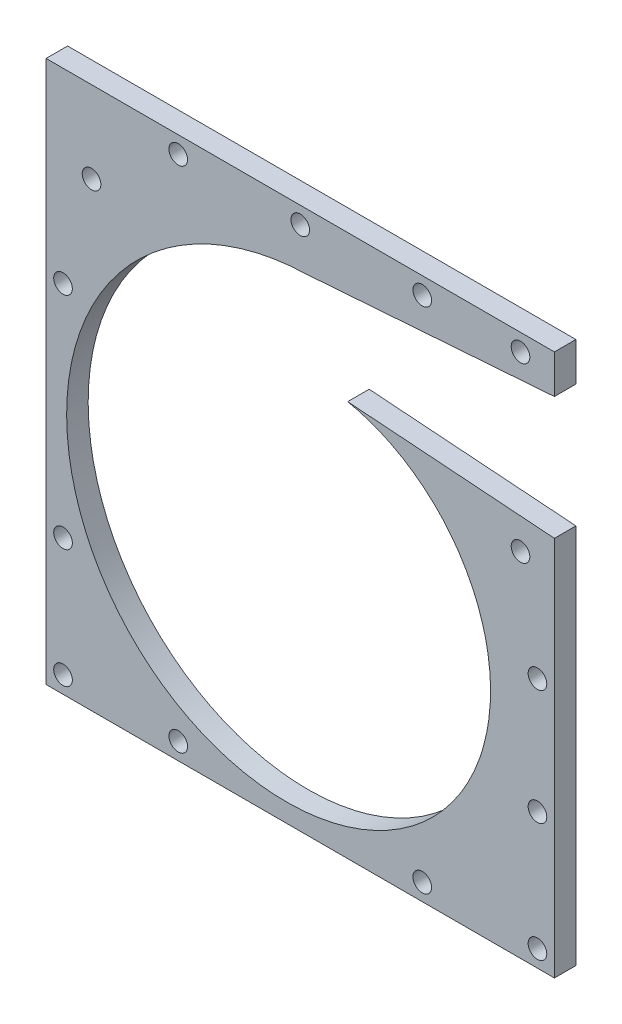
from build123d import *

# Parameters (mm, degrees)
SKETCH1_W           = 150
SKETCH1_H           = 160
BOSS_EXTRUDE1_DEPTH = 6.35
CUT_EXTRUDE2_REACH  = 8.35
SKETCH2_R           = 50
CUT_EXTRUDE3_REACH  = 8.35
CUT_EXTRUDE4_REACH  = 8.35
SKETCH9_R           = 2.75


with BuildPart() as part:
    # Sketch1 → Boss-Extrude1 (new body)
    with BuildSketch(Plane.XY):
        with Locations((56.818174671, 72.21769967)):
            Rectangle(SKETCH1_W, SKETCH1_H)
    extrude(amount=BOSS_EXTRUDE1_DEPTH)

    # Sketch2 → Cut-Extrude2 (cut, up to next)
    with BuildSketch(Plane.XY, mode=Mode.PRIVATE) as cut_extrude2_sk1:
        with Locations((56.818174671, 60.21769967)):
            Circle(SKETCH2_R)
    cut_extrude2_tool1 = extrude(cut_extrude2_sk1.sketch, amount=CUT_EXTRUDE2_REACH, mode=Mode.PRIVATE) & part.part
    add(cut_extrude2_tool1.solids().sort_by_distance((56.818175, 60.2177, 0))[0], mode=Mode.SUBTRACT)

    # Sketch8 → Cut-Extrude3 (cut, up to next)
    with BuildSketch(Plane.XY.offset(6.35), mode=Mode.PRIVATE) as cut_extrude3_sk1:
        with BuildLine():
            Line((58.92140003, 135.514331195), (131.818174671, 140.809388743))
            Line((131.818174671, 140.809388743), (131.818174671, 104.578808843))
            Line((131.818174671, 104.578808843), (70.806770479, 109.001730739))
            add(Edge.make_bspline(
                [(70.806770479, 109.001730739), (73.942524714, 108.368884336), (77.04178439, 107.432911602), (83.051183235, 104.970960127), (85.961176799, 103.444994734), (91.479272622, 99.84171719), (94.08723275, 97.764446671), (98.896476379, 93.118835241), (101.097626722, 90.550563372), (105.000601765, 85.003178114), (106.702307564, 82.024159237), (109.529682116, 75.752999351), (110.655251092, 72.460975365), (112.272876974, 65.675829551), (112.764857474, 62.18284337), (113.079726502, 55.118296179), (112.902565452, 51.546884758), (111.867369097, 44.454211174), (111.009313557, 40.93310722), (108.625399649, 34.071335338), (107.099551849, 30.730828472), (103.418128221, 24.357288168), (101.262594088, 21.324412639), (96.384092178, 15.685114778), (93.661196375, 13.078841183), (87.732775622, 8.399046081), (84.527350913, 6.325658336), (77.738594716, 2.80099297), (74.155388616, 1.34982877), (66.732312128, -0.861700607), (62.892588137, -1.621977418), (55.090144524, -2.406756839), (51.127587291, -2.431200011), (43.220919756, -1.725282069), (39.276982107, -0.994893308), (31.551721516, 1.212456983), (27.77057526, 2.689412638), (20.512525514, 6.354071351), (17.035796228, 8.541734506), (10.520379708, 13.56507488), (7.481857639, 16.400678926), (1.963709861, 22.631960147), (-0.515766072, 26.027532897), (-4.812661012, 33.268276111), (-6.629951535, 37.113314132), (-9.521205366, 45.123544829), (-10.595066712, 49.288581387), (-11.94355863, 57.794744944), (-12.218118102, 62.135697466), (-11.940081486, 70.8399882), (-11.387448434, 75.203139684), (-9.456713485, 83.793925735), (-8.078610826, 88.021368007), (-4.52880765, 96.184347178), (-2.357143331, 100.119693237), (2.718257783, 107.549380476), (5.621922023, 111.043539373), (12.071778181, 117.454666429), (15.617863156, 120.371467783), (23.237698029, 125.509870744), (27.311309881, 127.731327501), (35.849706709, 131.383908814), (40.314327037, 132.814916259), (49.481179121, 134.818294383), (54.183225201, 135.390580553), (58.92140003, 135.514331195)],
                knots=[0, 0, 0, 0, 0.03125, 0.03125, 0.0625, 0.0625, 0.09375, 0.09375, 0.125, 0.125, 0.15625, 0.15625, 0.1875, 0.1875, 0.21875, 0.21875, 0.25, 0.25, 0.28125, 0.28125, 0.3125, 0.3125, 0.34375, 0.34375, 0.375, 0.375, 0.40625, 0.40625, 0.4375, 0.4375, 0.46875, 0.46875, 0.5, 0.5, 0.53125, 0.53125, 0.5625, 0.5625, 0.59375, 0.59375, 0.625, 0.625, 0.65625, 0.65625, 0.6875, 0.6875, 0.71875, 0.71875, 0.75, 0.75, 0.78125, 0.78125, 0.8125, 0.8125, 0.84375, 0.84375, 0.875, 0.875, 0.90625, 0.90625, 0.9375, 0.9375, 0.96875, 0.96875, 1, 1, 1, 1], degree=3))
        make_face()
    cut_extrude3_tool1 = extrude(cut_extrude3_sk1.sketch, amount=-CUT_EXTRUDE3_REACH, mode=Mode.PRIVATE) & part.part
    add(cut_extrude3_tool1.solids().sort_by_distance((56.233786, 70.895416, 6.35))[0], mode=Mode.SUBTRACT)

    # Sketch9 → Cut-Extrude4 (cut, up to next)
    with BuildSketch(Plane.XY.offset(6.35), mode=Mode.PRIVATE) as cut_extrude4_sk1:
        with Locations((121.818174671, 147.21769967)):
            Circle(SKETCH9_R)
    cut_extrude4_tool1 = extrude(cut_extrude4_sk1.sketch, amount=-CUT_EXTRUDE4_REACH, mode=Mode.PRIVATE) & part.part
    add(cut_extrude4_tool1.solids().sort_by_distance((121.818175, 147.2177, 6.35))[0], mode=Mode.SUBTRACT)
    # Sketch9 → Cut-Extrude4 (cut, up to next)
    with BuildSketch(Plane.XY.offset(6.35), mode=Mode.PRIVATE) as cut_extrude4_sk2:
        with Locations((92.818174671, 147.21769967)):
            Circle(SKETCH9_R)
    cut_extrude4_tool2 = extrude(cut_extrude4_sk2.sketch, amount=-CUT_EXTRUDE4_REACH, mode=Mode.PRIVATE) & part.part
    add(cut_extrude4_tool2.solids().sort_by_distance((92.818175, 147.2177, 6.35))[0], mode=Mode.SUBTRACT)
    # Sketch9 → Cut-Extrude4 (cut, up to next)
    with BuildSketch(Plane.XY.offset(6.35), mode=Mode.PRIVATE) as cut_extrude4_sk3:
        with Locations((56.818174671, 147.21769967)):
            Circle(SKETCH9_R)
    cut_extrude4_tool3 = extrude(cut_extrude4_sk3.sketch, amount=-CUT_EXTRUDE4_REACH, mode=Mode.PRIVATE) & part.part
    add(cut_extrude4_tool3.solids().sort_by_distance((56.818175, 147.2177, 6.35))[0], mode=Mode.SUBTRACT)
    # Sketch9 → Cut-Extrude4 (cut, up to next)
    with BuildSketch(Plane.XY.offset(6.35), mode=Mode.PRIVATE) as cut_extrude4_sk4:
        with Locations((20.818174671, 147.21769967)):
            Circle(SKETCH9_R)
    cut_extrude4_tool4 = extrude(cut_extrude4_sk4.sketch, amount=-CUT_EXTRUDE4_REACH, mode=Mode.PRIVATE) & part.part
    add(cut_extrude4_tool4.solids().sort_by_distance((20.818175, 147.2177, 6.35))[0], mode=Mode.SUBTRACT)
    # Sketch9 → Cut-Extrude4 (cut, up to next)
    with BuildSketch(Plane.XY.offset(6.35), mode=Mode.PRIVATE) as cut_extrude4_sk5:
        with Locations((-4.774596198, 128.093555907)):
            Circle(SKETCH9_R)
    cut_extrude4_tool5 = extrude(cut_extrude4_sk5.sketch, amount=-CUT_EXTRUDE4_REACH, mode=Mode.PRIVATE) & part.part
    add(cut_extrude4_tool5.solids().sort_by_distance((-4.774596, 128.093556, 6.35))[0], mode=Mode.SUBTRACT)
    # Sketch9 → Cut-Extrude4 (cut, up to next)
    with BuildSketch(Plane.XY.offset(6.35), mode=Mode.PRIVATE) as cut_extrude4_sk6:
        with Locations((-13.181825329, 97.21769967)):
            Circle(SKETCH9_R)
    cut_extrude4_tool6 = extrude(cut_extrude4_sk6.sketch, amount=-CUT_EXTRUDE4_REACH, mode=Mode.PRIVATE) & part.part
    add(cut_extrude4_tool6.solids().sort_by_distance((-13.181825, 97.2177, 6.35))[0], mode=Mode.SUBTRACT)
    # Sketch9 → Cut-Extrude4 (cut, up to next)
    with BuildSketch(Plane.XY.offset(6.35), mode=Mode.PRIVATE) as cut_extrude4_sk7:
        with Locations((-13.181825329, 32.21769967)):
            Circle(SKETCH9_R)
    cut_extrude4_tool7 = extrude(cut_extrude4_sk7.sketch, amount=-CUT_EXTRUDE4_REACH, mode=Mode.PRIVATE) & part.part
    add(cut_extrude4_tool7.solids().sort_by_distance((-13.181825, 32.2177, 6.35))[0], mode=Mode.SUBTRACT)
    # Sketch9 → Cut-Extrude4 (cut, up to next)
    with BuildSketch(Plane.XY.offset(6.35), mode=Mode.PRIVATE) as cut_extrude4_sk8:
        with Locations((-13.181825329, -2.78230033)):
            Circle(SKETCH9_R)
    cut_extrude4_tool8 = extrude(cut_extrude4_sk8.sketch, amount=-CUT_EXTRUDE4_REACH, mode=Mode.PRIVATE) & part.part
    add(cut_extrude4_tool8.solids().sort_by_distance((-13.181825, -2.7823, 6.35))[0], mode=Mode.SUBTRACT)
    # Sketch9 → Cut-Extrude4 (cut, up to next)
    with BuildSketch(Plane.XY.offset(6.35), mode=Mode.PRIVATE) as cut_extrude4_sk9:
        with Locations((20.818174671, -2.78230033)):
            Circle(SKETCH9_R)
    cut_extrude4_tool9 = extrude(cut_extrude4_sk9.sketch, amount=-CUT_EXTRUDE4_REACH, mode=Mode.PRIVATE) & part.part
    add(cut_extrude4_tool9.solids().sort_by_distance((20.818175, -2.7823, 6.35))[0], mode=Mode.SUBTRACT)
    # Sketch9 → Cut-Extrude4 (cut, up to next)
    with BuildSketch(Plane.XY.offset(6.35), mode=Mode.PRIVATE) as cut_extrude4_sk10:
        with Locations((92.818174671, -2.78230033)):
            Circle(SKETCH9_R)
    cut_extrude4_tool10 = extrude(cut_extrude4_sk10.sketch, amount=-CUT_EXTRUDE4_REACH, mode=Mode.PRIVATE) & part.part
    add(cut_extrude4_tool10.solids().sort_by_distance((92.818175, -2.7823, 6.35))[0], mode=Mode.SUBTRACT)
    # Sketch9 → Cut-Extrude4 (cut, up to next)
    with BuildSketch(Plane.XY.offset(6.35), mode=Mode.PRIVATE) as cut_extrude4_sk11:
        with Locations((126.818174671, -2.78230033)):
            Circle(SKETCH9_R)
    cut_extrude4_tool11 = extrude(cut_extrude4_sk11.sketch, amount=-CUT_EXTRUDE4_REACH, mode=Mode.PRIVATE) & part.part
    add(cut_extrude4_tool11.solids().sort_by_distance((126.818175, -2.7823, 6.35))[0], mode=Mode.SUBTRACT)
    # Sketch9 → Cut-Extrude4 (cut, up to next)
    with BuildSketch(Plane.XY.offset(6.35), mode=Mode.PRIVATE) as cut_extrude4_sk12:
        with Locations((126.818174671, 32.21769967)):
            Circle(SKETCH9_R)
    cut_extrude4_tool12 = extrude(cut_extrude4_sk12.sketch, amount=-CUT_EXTRUDE4_REACH, mode=Mode.PRIVATE) & part.part
    add(cut_extrude4_tool12.solids().sort_by_distance((126.818175, 32.2177, 6.35))[0], mode=Mode.SUBTRACT)
    # Sketch9 → Cut-Extrude4 (cut, up to next)
    with BuildSketch(Plane.XY.offset(6.35), mode=Mode.PRIVATE) as cut_extrude4_sk13:
        with Locations((126.818174671, 66.21769967)):
            Circle(SKETCH9_R)
    cut_extrude4_tool13 = extrude(cut_extrude4_sk13.sketch, amount=-CUT_EXTRUDE4_REACH, mode=Mode.PRIVATE) & part.part
    add(cut_extrude4_tool13.solids().sort_by_distance((126.818175, 66.2177, 6.35))[0], mode=Mode.SUBTRACT)
    # Sketch9 → Cut-Extrude4 (cut, up to next)
    with BuildSketch(Plane.XY.offset(6.35), mode=Mode.PRIVATE) as cut_extrude4_sk14:
        with Locations((121.818174671, 96.21769967)):
            Circle(SKETCH9_R)
    cut_extrude4_tool14 = extrude(cut_extrude4_sk14.sketch, amount=-CUT_EXTRUDE4_REACH, mode=Mode.PRIVATE) & part.part
    add(cut_extrude4_tool14.solids().sort_by_distance((121.818175, 96.2177, 6.35))[0], mode=Mode.SUBTRACT)


solid = part.part
